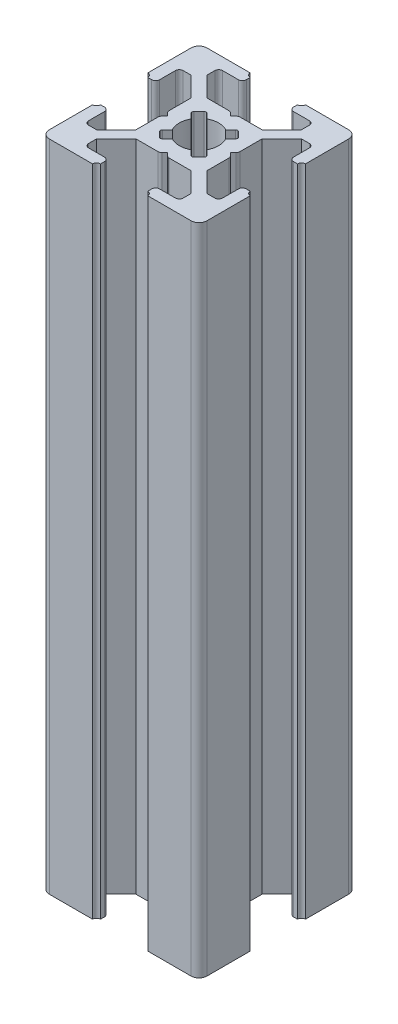
from build123d import *

# Parameters (mm, degrees)
BOSS_EXTRUDE1_DEPTH = 83
FILLET1_R           = 1
CUT_EXTRUDE1_DEPTH  = 84
FILLET2_R           = 0.5
FILLET3_R           = 0.25


with BuildPart() as part:
    # Sketch3 → Boss-Extrude1 (new body)
    with BuildSketch(Plane(origin=(0, 0, 0), x_dir=(1, 0, 0), z_dir=(0, 1, 0))):
        with BuildLine():
            Line((7, 18.5), (7, 19.5))
            ThreePointArc((7, 19.5), (6.646446609, 19.646446609), (6.5, 20))
            Line((6.5, 20), (0, 20))
            Line((0, 20), (0, 13.5))
            ThreePointArc((0, 13.5), (0.353553391, 13.353553391), (0.5, 13))
            Line((0.5, 13), (1.5, 13))
            Line((1.5, 13), (1.5, 16))
            Line((1.5, 16), (3, 16))
            Line((3, 16), (5.5, 13.5))
            Line((5.5, 13.5), (5.5, 10.5))
            Line((5.5, 10.5), (6, 10))
            Line((6, 10), (5.5, 9.5))
            Line((5.5, 9.5), (5.5, 6.5))
            Line((5.5, 6.5), (3, 4))
            Line((3, 4), (1.5, 4))
            Line((1.5, 4), (1.5, 7))
            Line((1.5, 7), (0.5, 7))
            ThreePointArc((0.5, 7), (0.353553391, 6.646446609), (0, 6.5))
            Line((0, 6.5), (0, 0))
            Line((0, 0), (6.5, 0))
            ThreePointArc((6.5, 0), (6.646446609, 0.353553391), (7, 0.5))
            Line((7, 0.5), (7, 1.5))
            Line((7, 1.5), (4, 1.5))
            Line((4, 1.5), (4, 3))
            Line((4, 3), (6.5, 5.5))
            Line((6.5, 5.5), (9.5, 5.5))
            Line((9.5, 5.5), (10, 6))
            Line((10, 6), (10.5, 5.5))
            Line((10.5, 5.5), (13.5, 5.5))
            Line((13.5, 5.5), (16, 3))
            Line((16, 3), (16, 1.5))
            Line((16, 1.5), (13, 1.5))
            Line((13, 1.5), (13, 0.5))
            ThreePointArc((13, 0.5), (13.353553391, 0.353553391), (13.5, 0))
            Line((13.5, 0), (20, 0))
            Line((20, 0), (20, 6.5))
            ThreePointArc((20, 6.5), (19.646446609, 6.646446609), (19.5, 7))
            Line((19.5, 7), (18.5, 7))
            Line((18.5, 7), (18.5, 4))
            Line((18.5, 4), (17, 4))
            Line((17, 4), (14.5, 6.5))
            Line((14.5, 6.5), (14.5, 9.5))
            Line((14.5, 9.5), (14, 10))
            Line((14, 10), (14.5, 10.5))
            Line((14.5, 10.5), (14.5, 13.5))
            Line((14.5, 13.5), (17, 16))
            Line((17, 16), (18.5, 16))
            Line((18.5, 16), (18.5, 13))
            Line((18.5, 13), (19.5, 13))
            ThreePointArc((19.5, 13), (19.646446609, 13.353553391), (20, 13.5))
            Line((20, 13.5), (20, 20))
            Line((20, 20), (13.5, 20))
            ThreePointArc((13.5, 20), (13.353553391, 19.646446609), (13, 19.5))
            Line((13, 19.5), (13, 18.5))
            Line((13, 18.5), (16, 18.5))
            Line((16, 18.5), (16, 17))
            Line((16, 17), (13.5, 14.5))
            Line((13.5, 14.5), (10.5, 14.5))
            Line((10.5, 14.5), (10, 14))
            Line((10, 14), (9.5, 14.5))
            Line((9.5, 14.5), (6.5, 14.5))
            Line((6.5, 14.5), (4, 17))
            Line((4, 17), (4, 18.5))
            Line((4, 18.5), (7, 18.5))
        make_face()
    extrude(amount=BOSS_EXTRUDE1_DEPTH)

    # Fillet1
    fillet1_edges = [part.edges().sort_by_distance(p)[0] for p in [
        (20, 41.5, 0),
        (0, 41.5, 0),
        (0, 41.5, -20),
        (20, 41.5, -20),
    ]]
    fillet(fillet1_edges, radius=FILLET1_R)

    # Sketch4 → Cut-Extrude1 (cut, through all)
    with BuildSketch(Plane(origin=(0, 83, 0), x_dir=(1, 0, 0), z_dir=(0, 1, 0))):
        with BuildLine():
            Line((10, 11), (11.195582496, 12.195582496))
            ThreePointArc((11.195582496, 12.195582496), (10, 12.5), (8.804417504, 12.195582496))
            Line((8.804417504, 12.195582496), (10, 11))
        make_face()
        with BuildLine():
            ThreePointArc((12.195582496, 11.195582496), (11.767766953, 11.767766953), (11.195582496, 12.195582496))
            Line((11.195582496, 12.195582496), (10, 11))
            Line((10, 11), (11, 10))
            Line((11, 10), (12.195582496, 11.195582496))
        make_face()
        with BuildLine():
            Line((9, 10), (10, 11))
            Line((10, 11), (8.804417504, 12.195582496))
            ThreePointArc((8.804417504, 12.195582496), (8.232233047, 11.767766953), (7.804417504, 11.195582496))
            Line((7.804417504, 11.195582496), (9, 10))
        make_face()
        Polygon((11, 10), (10, 11), (9, 10), (10, 9), align=None)
        with BuildLine():
            Line((7.804417504, 8.804417504), (9, 10))
            Line((9, 10), (7.804417504, 11.195582496))
            ThreePointArc((7.804417504, 11.195582496), (7.5, 10), (7.804417504, 8.804417504))
        make_face()
        with BuildLine():
            Line((10, 9), (9, 10))
            Line((9, 10), (7.804417504, 8.804417504))
            ThreePointArc((7.804417504, 8.804417504), (8.232233047, 8.232233047), (8.804417504, 7.804417504))
            Line((8.804417504, 7.804417504), (10, 9))
        make_face()
        with BuildLine():
            Line((11.195582496, 7.804417504), (10, 9))
            Line((10, 9), (8.804417504, 7.804417504))
            ThreePointArc((8.804417504, 7.804417504), (10, 7.5), (11.195582496, 7.804417504))
        make_face()
        with BuildLine():
            Line((12.195582496, 8.804417504), (11, 10))
            Line((11, 10), (10, 9))
            Line((10, 9), (11.195582496, 7.804417504))
            ThreePointArc((11.195582496, 7.804417504), (11.767766953, 8.232233047), (12.195582496, 8.804417504))
        make_face()
        with BuildLine():
            ThreePointArc((12.5, 10), (12.422700584, 10.616864556), (12.195582496, 11.195582496))
            Line((12.195582496, 11.195582496), (11, 10))
            Line((11, 10), (12.195582496, 8.804417504))
            ThreePointArc((12.195582496, 8.804417504), (12.422700584, 9.383135444), (12.5, 10))
        make_face()
        with BuildLine():
            ThreePointArc((8.804417504, 7.804417504), (8.232233047, 8.232233047), (7.804417504, 8.804417504))
            Line((7.804417504, 8.804417504), (7, 8))
            Line((7, 8), (8, 7))
            Line((8, 7), (8.804417504, 7.804417504))
        make_face()
        with BuildLine():
            Line((13, 8), (12.195582496, 8.804417504))
            ThreePointArc((12.195582496, 8.804417504), (11.767766953, 8.232233047), (11.195582496, 7.804417504))
            Line((11.195582496, 7.804417504), (12, 7))
            Line((12, 7), (13, 8))
        make_face()
        with BuildLine():
            Line((13, 12), (12, 13))
            Line((12, 13), (11.195582496, 12.195582496))
            ThreePointArc((11.195582496, 12.195582496), (11.767766953, 11.767766953), (12.195582496, 11.195582496))
            Line((12.195582496, 11.195582496), (13, 12))
        make_face()
        with BuildLine():
            ThreePointArc((7.804417504, 11.195582496), (8.232233047, 11.767766953), (8.804417504, 12.195582496))
            Line((8.804417504, 12.195582496), (8, 13))
            Line((8, 13), (7, 12))
            Line((7, 12), (7.804417504, 11.195582496))
        make_face()
    extrude(amount=-CUT_EXTRUDE1_DEPTH, mode=Mode.SUBTRACT)

    # Fillet2
    fillet2_edges = [part.edges().sort_by_distance(p)[0] for p in [
        (18.5, 41.5, -13),
        (18.5, 41.5, -16),
        (14.5, 41.5, -10.5),
        (14.5, 41.5, -9.5),
        (18.5, 41.5, -4),
        (18.5, 41.5, -7),
        (13, 41.5, -1.5),
        (16, 41.5, -1.5),
        (10.5, 41.5, -5.5),
        (9.5, 41.5, -5.5),
        (4, 41.5, -1.5),
        (7, 41.5, -1.5),
        (1.5, 41.5, -7),
        (1.5, 41.5, -4),
        (5.5, 41.5, -9.5),
        (5.5, 41.5, -10.5),
        (1.5, 41.5, -16),
        (1.5, 41.5, -13),
        (7, 41.5, -18.5),
        (4, 41.5, -18.5),
        (9.5, 41.5, -14.5),
        (10.5, 41.5, -14.5),
        (16, 41.5, -18.5),
        (13, 41.5, -18.5),
    ]]
    fillet(fillet2_edges, radius=FILLET2_R)

    # Fillet3
    fillet3_edges = [part.edges().sort_by_distance(p)[0] for p in [
        (7, 41.5, -12),
        (8, 41.5, -13),
        (12, 41.5, -13),
        (13, 41.5, -12),
        (13, 41.5, -8),
        (12, 41.5, -7),
        (8, 41.5, -7),
        (7, 41.5, -8),
    ]]
    fillet(fillet3_edges, radius=FILLET3_R)


solid = part.part
